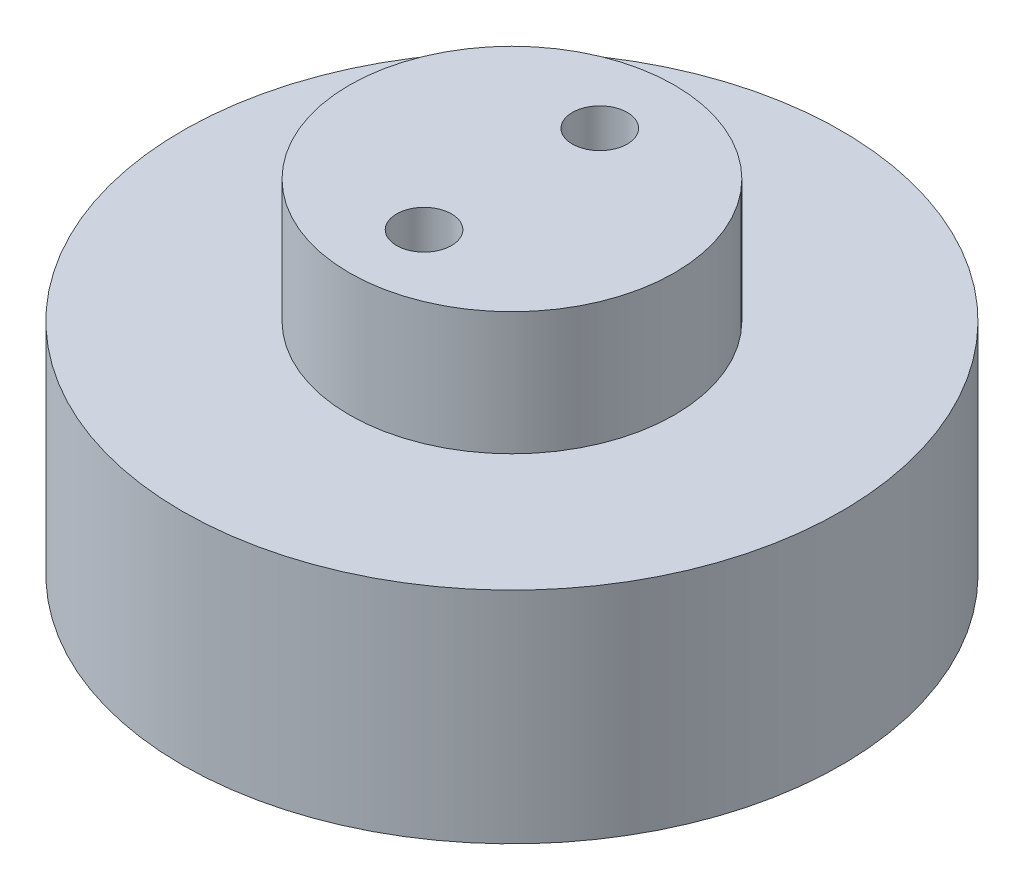
from build123d import *

# Parameters (mm, degrees)
SKETCH1_R           = 19.05
BOSS_EXTRUDE1_DEPTH = 12.7
SKETCH2_R           = 9.398
BOSS_EXTRUDE2_DEPTH = 7.112
CUT_EXTRUDE3_DEPTH  = 3.175
SKETCH6_R           = 1.5875
CUT_EXTRUDE4_DEPTH  = 7.62
SKETCH7_R           = 2.921
CUT_EXTRUDE5_DEPTH  = 17.272
SKETCH8_R           = 1.5875
CUT_EXTRUDE6_DEPTH  = 3.54


with BuildPart() as part:
    # Sketch1 → Boss-Extrude1 (new body)
    with BuildSketch(Plane(origin=(0, 0, 0), x_dir=(1, 0, 0), z_dir=(0, 1, 0))):
        Circle(SKETCH1_R)
    extrude(amount=BOSS_EXTRUDE1_DEPTH)

    # Sketch2 → Boss-Extrude2 (add)
    with BuildSketch(Plane(origin=(0, 12.7, 0), x_dir=(1, 0, 0), z_dir=(0, 1, 0))):
        Circle(SKETCH2_R)
    extrude(amount=BOSS_EXTRUDE2_DEPTH)

    # Sketch5 → Cut-Extrude3 (cut)
    with BuildSketch(Plane.XZ):
        Polygon((-5.393973528, 0), (-7.776986764, 4.1275), (-12.543013236, 4.1275), (-14.926026472, 0), (-12.543013236, -4.1275), (-7.776986764, -4.1275), align=None)
        Polygon((14.926026472, 0), (12.543013236, 4.1275), (7.776986764, 4.1275), (5.393973528, 0), (7.776986764, -4.1275), (12.543013236, -4.1275), align=None)
    extrude(amount=-CUT_EXTRUDE3_DEPTH, mode=Mode.SUBTRACT)

    # Sketch6 → Cut-Extrude4 (cut)
    with BuildSketch(Plane.XZ):
        with Locations((-10.16, 0)):
            Circle(SKETCH6_R)
        with Locations((10.16, 0)):
            Circle(SKETCH6_R)
    extrude(amount=-CUT_EXTRUDE4_DEPTH, mode=Mode.SUBTRACT)

    # Sketch7 → Cut-Extrude5 (cut)
    with BuildSketch(Plane.XZ):
        with Locations((0, 5.08)):
            Circle(SKETCH7_R)
        with Locations((0, -5.08)):
            Circle(SKETCH7_R)
    extrude(amount=-CUT_EXTRUDE5_DEPTH, mode=Mode.SUBTRACT)

    # Sketch8 → Cut-Extrude6 (cut, through all)
    with BuildSketch(Plane.XZ.offset(-17.272)):
        with Locations((0, 5.08)):
            Circle(SKETCH8_R)
        with Locations((0, -5.08)):
            Circle(SKETCH8_R)
    extrude(amount=-CUT_EXTRUDE6_DEPTH, mode=Mode.SUBTRACT)


solid = part.part
